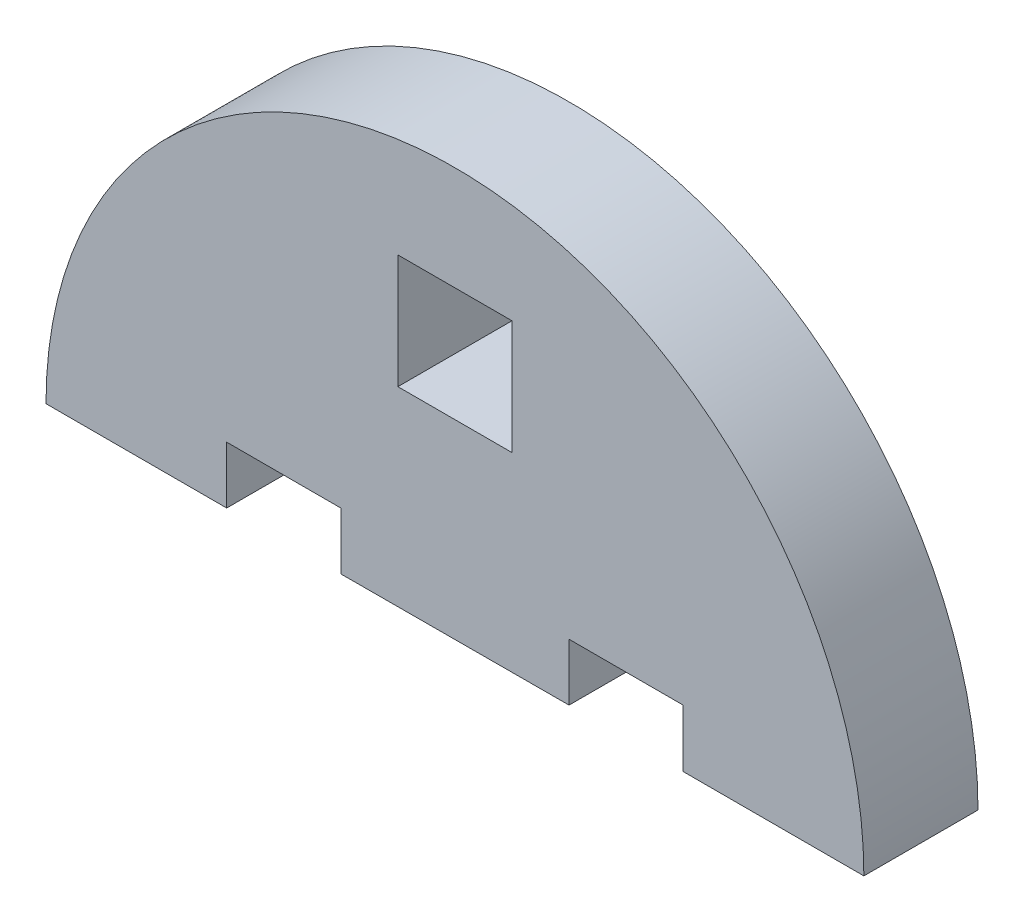
from build123d import *

# Parameters (mm, degrees)
MODEL_W             = 6
MODEL_H             = 6
BOSS_EXTRUDE1_DEPTH = 6


with BuildPart() as part:
    # Model → Boss-Extrude1 (new body)
    with BuildSketch(Plane.XY):
        with BuildLine():
            Line((3925.531656445, 1073.487893097), (3916.031656445, 1073.487893097))
            Line((3916.031656445, 1073.487893097), (3916.0316001, 1076.513895594))
            Line((3916.0316001, 1076.513895594), (3910.0316001, 1076.513895594))
            Line((3910.0316001, 1076.513895594), (3910.0316001, 1073.513895594))
            Line((3910.0316001, 1073.513895594), (3898.031656445, 1073.487893097))
            Line((3898.031656445, 1073.487893097), (3898.031656445, 1076.487893097))
            Line((3898.031656445, 1076.487893097), (3892.031656445, 1076.487893097))
            Line((3892.031656445, 1076.487893097), (3892.031656445, 1073.487893097))
            Line((3892.031656445, 1073.487893097), (3882.531656445, 1073.487893097))
            ThreePointArc((3882.531656445, 1073.487893097), (3904.031656445, 1094.987893097), (3925.531656445, 1073.487893097))
        make_face()
        with Locations((3904.0316001, 1086.513895594)):
            Rectangle(MODEL_W, MODEL_H, mode=Mode.SUBTRACT)
    extrude(amount=BOSS_EXTRUDE1_DEPTH)


solid = part.part
